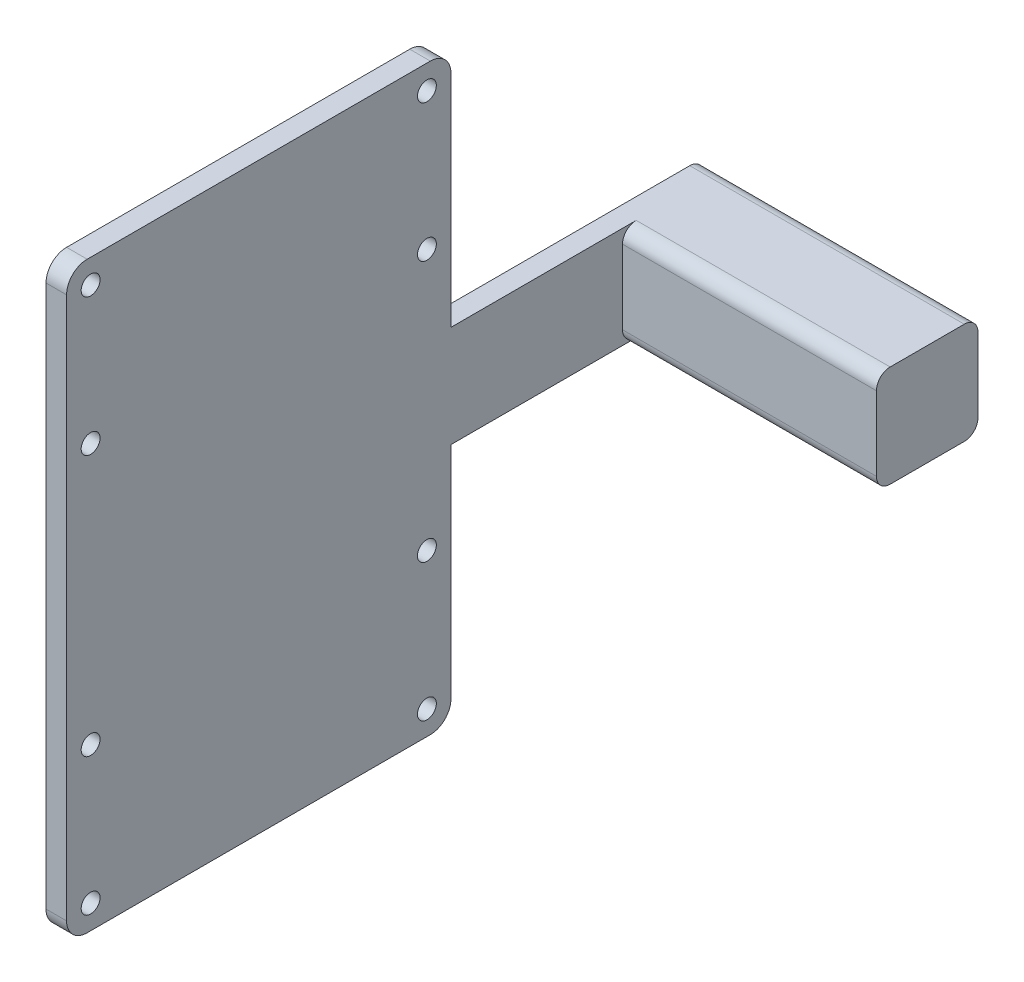
from build123d import *

# Parameters (mm, degrees)
SKETCH1_W           = 40
SKETCH1_H           = 14.8
BOSS_EXTRUDE1_DEPTH = 14.8
SKETCH3_W           = 3
SKETCH3_H           = 14.8
BOSS_EXTRUDE3_DEPTH = 25
SKETCH5_W           = 3
SKETCH5_H           = 85
BOSS_EXTRUDE4_DEPTH = 56
SKETCH6_R           = 1.375
CUT_EXTRUDE1_DEPTH  = 5
FILLET2_R           = 3
FILLET3_R           = 2


with BuildPart() as part:
    # Sketch1 → Boss-Extrude1 (new body)
    with BuildSketch(Plane.XY):
        Rectangle(SKETCH1_W, SKETCH1_H)
    extrude(amount=BOSS_EXTRUDE1_DEPTH)

    # Sketch3 → Boss-Extrude3 (add)
    with BuildSketch(Plane.XY.offset(14.8)):
        with Locations((-18.5, 0)):
            Rectangle(SKETCH3_W, SKETCH3_H)
    extrude(amount=BOSS_EXTRUDE3_DEPTH)

    # Sketch5 → Boss-Extrude4 (add)
    with BuildSketch(Plane.XY.offset(39.8)):
        with Locations((-18.5, 0)):
            Rectangle(SKETCH5_W, SKETCH5_H)
    extrude(amount=BOSS_EXTRUDE4_DEPTH)

    # Sketch6 → Cut-Extrude1 (cut)
    with BuildSketch(Plane(origin=(-17, 0, 0), x_dir=(0, 0, -1), z_dir=(1, 0, 0))):
        with Locations((-92.3, 39)):
            Circle(SKETCH6_R)
        with Locations((-43.3, 39)):
            Circle(SKETCH6_R)
        with Locations((-43.3, -19)):
            Circle(SKETCH6_R)
        with Locations((-92.3, -19)):
            Circle(SKETCH6_R)
    cut_extrude1 = extrude(amount=-CUT_EXTRUDE1_DEPTH, mode=Mode.SUBTRACT)

    # Fillet2
    fillet2_edges = [part.edges().sort_by_distance(p)[0] for p in [
        (-18.5, -42.5, 39.8),
        (-18.5, 42.5, 39.8),
        (-18.5, -42.5, 95.8),
        (-18.5, 42.5, 95.8),
    ]]
    fillet(fillet2_edges, radius=FILLET2_R)

    # Mirror1: Cut-Extrude1 across plane
    add(cut_extrude1.mirror(Plane.ZX), mode=Mode.SUBTRACT)

    # Fillet3
    fillet3_edges = [part.edges().sort_by_distance(p)[0] for p in [
        (1.5, 7.4, 14.8),
        (1.5, -7.4, 14.8),
        (0, 7.4, 0),
        (0, -7.4, 0),
    ]]
    fillet(fillet3_edges, radius=FILLET3_R)


solid = part.part
